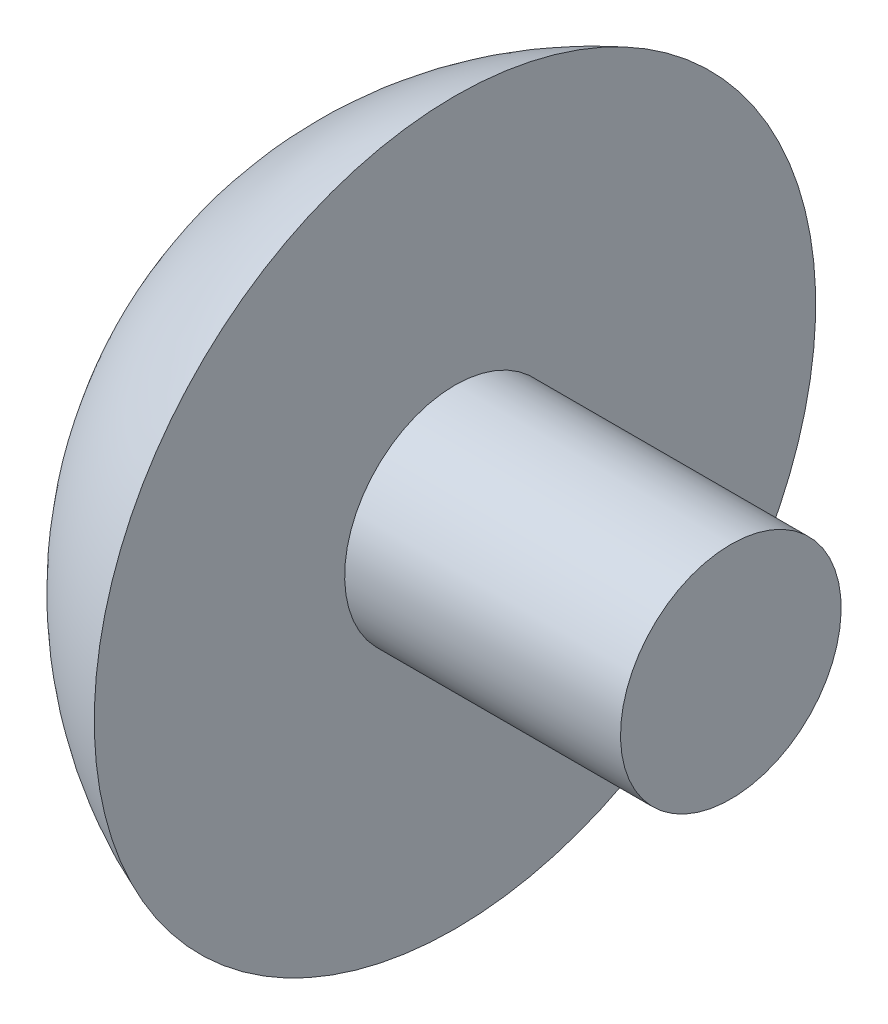
from build123d import *


with BuildPart() as part:
    # Esquisse5 → Révolution2 (revolve)
    with BuildSketch(Plane.XY):
        with BuildLine():
            Line((0, 0), (-9.5, 0))
            ThreePointArc((-9.5, 0), (-8.266281297, -3.968626967), (-5, -6.538348415))
            Line((-5, -6.538348415), (-5, -2))
            Line((-5, -2), (0, -2))
            Line((0, -2), (0, 0))
        make_face()
    revolve(axis=Axis((0, 0, 0), (-1, 0, 0)))


solid = part.part
